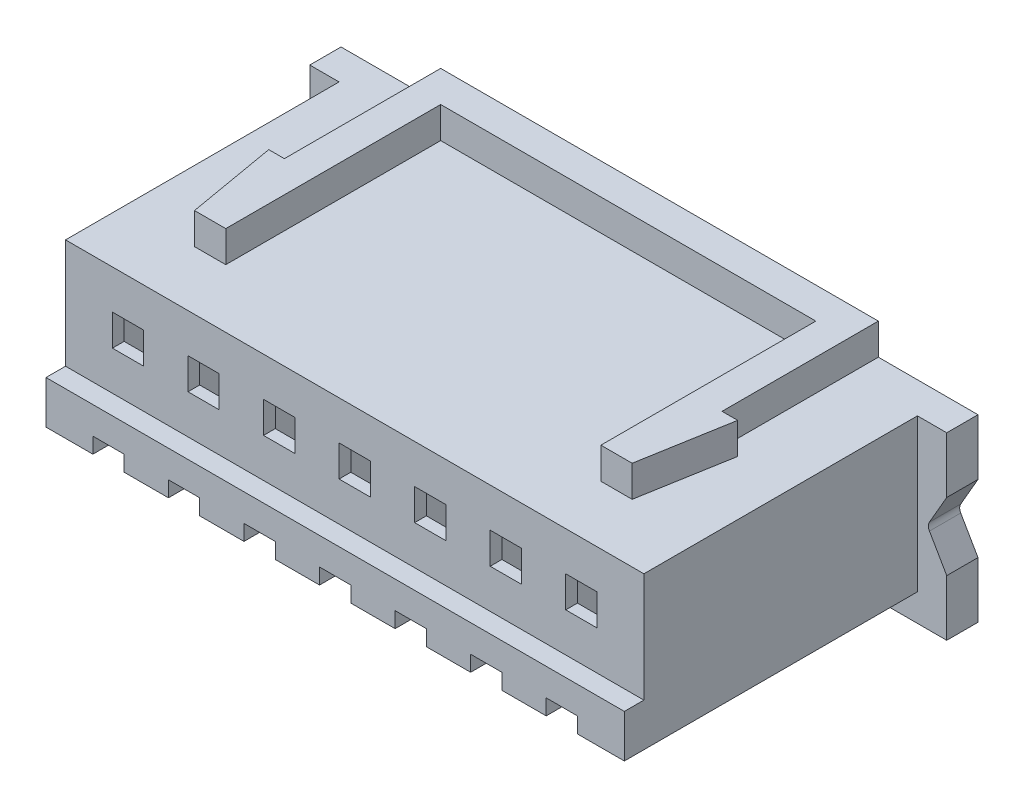
from build123d import *

# Parameters (mm, degrees)
SKETCH1_W           = 14.8
SKETCH1_H           = 4.3
BOSS_EXTRUDE1_DEPTH = 7
SKETCH2_W           = 16.3
SKETCH2_H           = 4.6
BOSS_EXTRUDE2_DEPTH = 0.8
CUT_EXTRUDE1_DEPTH  = 1
FILLET1_R           = 0.2
SKETCH4_W           = 14.8
SKETCH4_H           = 1.5
BOSS_EXTRUDE3_DEPTH = 0.5
SKETCH5_W           = 0.8
SKETCH5_H           = 0.8
CUT_EXTRUDE2_DEPTH  = 3.2
SKETCH6_W           = 0.8
SKETCH6_H           = 0.8
CUT_EXTRUDE3_DEPTH  = 10
BOSS_EXTRUDE4_DEPTH = 0.8
CUT_EXTRUDE4_DEPTH  = 7.5
CUT_EXTRUDE5_DEPTH  = 0.4
BOSS_EXTRUDE5_DEPTH = 0.1


with BuildPart() as part:
    # Sketch1 → Boss-Extrude1 (new body)
    with BuildSketch(Plane.XY):
        Rectangle(SKETCH1_W, SKETCH1_H)
    extrude(amount=BOSS_EXTRUDE1_DEPTH)

    # Sketch2 → Boss-Extrude2 (add)
    with BuildSketch(Plane(origin=(0, 0, 0), x_dir=(-1, 0, 0), z_dir=(0, 0, -1))):
        with Locations((0, -0.15)):
            Rectangle(SKETCH2_W, SKETCH2_H)
    extrude(amount=BOSS_EXTRUDE2_DEPTH)

    # Sketch3 → Cut-Extrude1 (cut)
    with BuildSketch(Plane.XY):
        Polygon((7.65, -0.15), (8.15, -1.016025404), (8.15, 0.716025404), align=None)
    extrude(amount=-CUT_EXTRUDE1_DEPTH, mode=Mode.SUBTRACT)

    # Fillet1
    fillet1_edges = [part.edges().sort_by_distance(p)[0] for p in [
        (7.65, -0.15, -0.4),
    ]]
    fillet(fillet1_edges, radius=FILLET1_R)

    # Sketch4 → Boss-Extrude3 (add)
    with BuildSketch(Plane.XY.offset(7)):
        with Locations((0, -1.4)):
            Rectangle(SKETCH4_W, SKETCH4_H)
    extrude(amount=BOSS_EXTRUDE3_DEPTH)

    # Sketch5 → Cut-Extrude2 (cut)
    with BuildSketch(Plane.XY.offset(7.5)):
        with Locations((3.866666667, -1.75)):
            Rectangle(SKETCH5_W, SKETCH5_H)
        with Locations((1.933333333, -1.75)):
            Rectangle(SKETCH5_W, SKETCH5_H)
        with Locations((0, -1.75)):
            Rectangle(SKETCH5_W, SKETCH5_H)
        with Locations((-1.933333333, -1.75)):
            Rectangle(SKETCH5_W, SKETCH5_H)
        with Locations((5.8, -1.75)):
            Rectangle(SKETCH5_W, SKETCH5_H)
        with Locations((-3.866666667, -1.75)):
            Rectangle(SKETCH5_W, SKETCH5_H)
        with Locations((-5.8, -1.75)):
            Rectangle(SKETCH5_W, SKETCH5_H)
    extrude(amount=-CUT_EXTRUDE2_DEPTH, mode=Mode.SUBTRACT)

    # Sketch6 → Cut-Extrude3 (cut)
    with BuildSketch(Plane.XY.offset(7)):
        with Locations((-5.8, 0.75)):
            Rectangle(SKETCH6_W, SKETCH6_H)
        with Locations((-3.866666667, 0.75)):
            Rectangle(SKETCH6_W, SKETCH6_H)
        with Locations((-1.933333333, 0.75)):
            Rectangle(SKETCH6_W, SKETCH6_H)
        with Locations((0, 0.75)):
            Rectangle(SKETCH6_W, SKETCH6_H)
        with Locations((1.933333333, 0.75)):
            Rectangle(SKETCH6_W, SKETCH6_H)
        with Locations((3.866666667, 0.75)):
            Rectangle(SKETCH6_W, SKETCH6_H)
        with Locations((5.8, 0.75)):
            Rectangle(SKETCH6_W, SKETCH6_H)
    extrude(amount=-CUT_EXTRUDE3_DEPTH, mode=Mode.SUBTRACT)

    # Sketch7 → Boss-Extrude4 (add)
    with BuildSketch(Plane(origin=(0, 2.15, 0), x_dir=(1, 0, 0), z_dir=(0, 1, 0))):
        Polygon((-5.6, -5.5), (-6, -3.2), (-5.6, -3.2), (-5.6, 0.8), (5.6, 0.8), (5.6, -3.2), (6, -3.2), (5.6, -5.5), (4.8, -5.5), (4.8, 0), (-4.8, 0), (-4.8, -5.5), align=None)
    extrude(amount=BOSS_EXTRUDE4_DEPTH)

    # Sketch8 → Cut-Extrude4 (cut)
    with BuildSketch(Plane(origin=(0, 0, -0.8), x_dir=(-1, 0, 0), z_dir=(0, 0, -1))):
        Polygon((4.8, 1.85), (2.933333333, 1.85), (2.933333333, -0.95), (3.466666667, -0.95), (3.466666667, -1.35), (4.266666667, -1.35), (4.266666667, -0.95), (4.8, -0.95), align=None)
        Polygon((6.8, 1.85), (4.866666667, 1.85), (4.866666667, -0.95), (5.4, -0.95), (5.4, -1.35), (6.2, -1.35), (6.2, -0.95), (6.8, -0.95), align=None)
        Polygon((2.866666667, 1.85), (2.866666667, -0.95), (2.333333333, -0.95), (2.333333333, -1.35), (1.533333333, -1.35), (1.533333333, -0.95), (1, -0.95), (1, 1.85), align=None)
        Polygon((0.933333333, 1.85), (0.933333333, -0.95), (0.4, -0.95), (0.4, -1.35), (-0.4, -1.35), (-0.4, -0.95), (-0.933333333, -0.95), (-0.933333333, 1.85), align=None)
        Polygon((-1, 1.85), (-1, -0.95), (-1.533333333, -0.95), (-1.533333333, -1.35), (-2.333333333, -1.35), (-2.333333333, -0.95), (-2.866666667, -0.95), (-2.866666667, 1.85), align=None)
        Polygon((-2.933333333, 1.85), (-2.933333333, -0.95), (-3.466666667, -0.95), (-3.466666667, -1.35), (-4.266666667, -1.35), (-4.266666667, -0.95), (-4.8, -0.95), (-4.8, 1.85), align=None)
        Polygon((-4.866666667, 1.85), (-4.866666667, -0.95), (-5.4, -0.95), (-5.4, -1.35), (-6.2, -1.35), (-6.2, -0.95), (-6.8, -0.95), (-6.8, 1.85), align=None)
    extrude(amount=-CUT_EXTRUDE4_DEPTH, mode=Mode.SUBTRACT)

    # Sketch9 → Cut-Extrude5 (cut)
    with BuildSketch(Plane.XZ.offset(2.15)):
        Polygon((-6.2, 7.5), (-7.4, 7.5), (-7.4, 0), (7.4, 0), (7.4, 7.5), (6.2, 7.5), (6.2, 4.3), (5.4, 4.3), (5.4, 7.5), (4.266666667, 7.5), (4.266666667, 4.3), (3.466666667, 4.3), (3.466666667, 7.5), (2.333333333, 7.5), (2.333333333, 4.3), (1.533333333, 4.3), (1.533333333, 7.5), (0.4, 7.5), (0.4, 4.3), (-0.4, 4.3), (-0.4, 7.5), (-1.533333333, 7.5), (-1.533333333, 4.3), (-2.333333333, 4.3), (-2.333333333, 7.5), (-3.466666667, 7.5), (-3.466666667, 4.3), (-4.266666667, 4.3), (-4.266666667, 7.5), (-5.4, 7.5), (-5.4, 4.3), (-6.2, 4.3), align=None)
    extrude(amount=-CUT_EXTRUDE5_DEPTH, mode=Mode.SUBTRACT)

    # Sketch10 → Boss-Extrude5 (add)
    with BuildSketch(Plane(origin=(0, 0, -0.8), x_dir=(-1, 0, 0), z_dir=(0, 0, -1))):
        Polygon((-5.805978759, -1.515739488), (-5.713530843, -1.515739488), (-5.713530843, -2.015739488), (-5.758402638, -2.015739488), (-5.758402638, -1.567021539), (-5.835325715, -1.567021539), align=None)
        with BuildLine():
            Line((-3.925069304, -1.669585642), (-3.969941099, -1.669585642))
            add(Edge.make_bspline(
                [(-3.969941099, -1.669585642), (-3.969648649, -1.663632658), (-3.969074284, -1.651941156), (-3.966384528, -1.634894883), (-3.962535832, -1.618601341), (-3.957094195, -1.603191353), (-3.950336156, -1.588528666), (-3.942231866, -1.574671521), (-3.932632744, -1.56167278), (-3.921746068, -1.549652945), (-3.909921977, -1.538626149), (-3.897163986, -1.529103972), (-3.883757553, -1.52105859), (-3.869743353, -1.514332698), (-3.854963273, -1.509284149), (-3.839551436, -1.505538201), (-3.823440131, -1.503284437), (-3.812462985, -1.503042182), (-3.806880202, -1.502918975)],
                knots=[0, 0, 0, 0, 1.7869e-05, 3.5094e-05, 5.1686e-05, 6.8032e-05, 8.4031e-05, 0.000100058, 0.000116104, 0.000132416, 0.000148647, 0.000164532, 0.000180078, 0.00019549, 0.000211074, 0.000226841, 0.000243017, 0.000259759, 0.000259759, 0.000259759, 0.000259759], degree=3))
            add(Edge.make_bspline(
                [(-3.806880202, -1.502918975), (-3.80139762, -1.503047326), (-3.790624542, -1.503299531), (-3.774901397, -1.505465392), (-3.759933212, -1.50885762), (-3.745749245, -1.513616965), (-3.732462665, -1.52001474), (-3.719973658, -1.527700103), (-3.708133543, -1.53658865), (-3.697475431, -1.547053481), (-3.687688562, -1.55822525), (-3.679245383, -1.570152093), (-3.672014931, -1.582470563), (-3.66598812, -1.595274592), (-3.661551528, -1.608684738), (-3.658183213, -1.622505767), (-3.656279297, -1.63688074), (-3.655987093, -1.646610248), (-3.655838535, -1.651556796)],
                knots=[0, 0, 0, 0, 1.6441e-05, 3.2306e-05, 4.7516e-05, 6.2435e-05, 7.7085e-05, 9.1652e-05, 0.000106376, 0.000121393, 0.000136374, 0.000150882, 0.000165157, 0.000179183, 0.000193247, 0.000207458, 0.000221808, 0.000236648, 0.000236648, 0.000236648, 0.000236648], degree=3))
            add(Edge.make_bspline(
                [(-3.655838535, -1.651556796), (-3.65608043, -1.658520772), (-3.656559974, -1.672326517), (-3.660662028, -1.692614354), (-3.667068673, -1.712270557), (-3.674782581, -1.728090172), (-3.682564358, -1.740837814), (-3.689576859, -1.751333343), (-3.697786118, -1.762634124), (-3.707311618, -1.774702315), (-3.717956314, -1.787632444), (-3.729816623, -1.801416701), (-3.74297712, -1.815912668), (-3.752214049, -1.825813468), (-3.757000394, -1.830943815)],
                knots=[0, 0, 0, 0, 2.0874e-05, 4.1382e-05, 6.1843e-05, 8.2763e-05, 9.3997e-05, 0.000106637, 0.000120621, 0.000135888, 0.000152753, 0.000170863, 0.000190435, 0.000211484, 0.000211484, 0.000211484, 0.000211484], degree=3))
            Line((-3.757000394, -1.830943815), (-3.882100554, -1.964457437))
            Line((-3.882100554, -1.964457437), (-3.649428279, -1.964457437))
            Line((-3.649428279, -1.964457437), (-3.649428279, -2.015739488))
            Line((-3.649428279, -2.015739488), (-3.989171868, -2.015739488))
            Line((-3.989171868, -2.015739488), (-3.795261612, -1.808808398))
            add(Edge.make_bspline(
                [(-3.795261612, -1.808808398), (-3.790540485, -1.803880069), (-3.781472167, -1.794413756), (-3.768646085, -1.780593333), (-3.757126229, -1.76777197), (-3.74683803, -1.755973892), (-3.738004672, -1.745026525), (-3.730165782, -1.735284425), (-3.723884983, -1.726319503), (-3.717068498, -1.715927987), (-3.710466501, -1.703240513), (-3.704793307, -1.6877357), (-3.701334043, -1.671774664), (-3.700919067, -1.660988659), (-3.70071033, -1.655563206)],
                knots=[0, 0, 0, 0, 2.0474e-05, 3.9327e-05, 5.6561e-05, 7.2184e-05, 8.6278e-05, 9.8762e-05, 0.000109683, 0.000119101, 0.000136035, 0.000152448, 0.000168517, 0.00018478, 0.00018478, 0.00018478, 0.00018478], degree=3))
            add(Edge.make_bspline(
                [(-3.70071033, -1.655563206), (-3.70080115, -1.652151578), (-3.70098014, -1.645427913), (-3.702559811, -1.635569948), (-3.704947026, -1.626060689), (-3.708367777, -1.616870886), (-3.712883026, -1.608092935), (-3.718379223, -1.599716153), (-3.72472066, -1.591617729), (-3.732056556, -1.584024401), (-3.740115345, -1.577069943), (-3.748628809, -1.570909359), (-3.757635967, -1.565760915), (-3.767098841, -1.561540415), (-3.776991051, -1.558229646), (-3.787331729, -1.555935564), (-3.798092303, -1.554495209), (-3.805439945, -1.554300327), (-3.809183888, -1.554201026)],
                knots=[0, 0, 0, 0, 1.0229e-05, 2.0159e-05, 2.9876e-05, 3.9606e-05, 4.9505e-05, 5.9423e-05, 6.9622e-05, 8.0319e-05, 9.1042e-05, 0.000101521, 0.000111795, 0.000122107, 0.000132559, 0.000143032, 0.000153841, 0.00016507, 0.00016507, 0.00016507, 0.00016507], degree=3))
            add(Edge.make_bspline(
                [(-3.809183888, -1.554201026), (-3.813094007, -1.554303174), (-3.820772835, -1.554503775), (-3.832046982, -1.555907012), (-3.842802093, -1.558327847), (-3.853065222, -1.5616388), (-3.862853735, -1.565847164), (-3.872120027, -1.571088842), (-3.880843296, -1.577343627), (-3.889039943, -1.584435135), (-3.89659194, -1.592330506), (-3.903227208, -1.60113193), (-3.909024924, -1.610678703), (-3.914083386, -1.620945068), (-3.918191342, -1.632024179), (-3.921330363, -1.643876708), (-3.923814198, -1.656451192), (-3.924643987, -1.665134775), (-3.925069304, -1.669585642)],
                knots=[0, 0, 0, 0, 1.1729e-05, 2.3035e-05, 3.4018e-05, 4.4756e-05, 5.5343e-05, 6.5928e-05, 7.6628e-05, 8.7492e-05, 9.8403e-05, 0.00010934, 0.000120489, 0.000131867, 0.000143625, 0.00015587, 0.000168619, 0.000182025, 0.000182025, 0.000182025, 0.000182025], degree=3))
        make_face()
        with BuildLine():
            Line((-2.001992381, -1.631124103), (-2.046864176, -1.631124103))
            add(Edge.make_bspline(
                [(-2.046864176, -1.631124103), (-2.045648526, -1.626090891), (-2.04327203, -1.616251374), (-2.038315233, -1.602193193), (-2.03291534, -1.588889833), (-2.026431182, -1.576590394), (-2.019358503, -1.565047694), (-2.011255257, -1.554523533), (-2.002495296, -1.544750252), (-1.992806018, -1.536076933), (-1.982644781, -1.528222971), (-1.971868406, -1.521526535), (-1.960693707, -1.515765941), (-1.94904326, -1.511020194), (-1.936882378, -1.507445119), (-1.924321003, -1.50485129), (-1.911326218, -1.503166845), (-1.902505133, -1.50300245), (-1.898026035, -1.502918975)],
                knots=[0, 0, 0, 0, 1.5524e-05, 3.0347e-05, 4.467e-05, 5.8558e-05, 7.201e-05, 8.5231e-05, 9.8349e-05, 0.000111325, 0.000124187, 0.000136831, 0.000149329, 0.000161865, 0.00017451, 0.000187298, 0.000200318, 0.000213748, 0.000213748, 0.000213748, 0.000213748], degree=3))
            add(Edge.make_bspline(
                [(-1.898026035, -1.502918975), (-1.891499929, -1.503116008), (-1.87859007, -1.503505776), (-1.859623921, -1.507064981), (-1.841334375, -1.512697143), (-1.823921626, -1.520479104), (-1.807747564, -1.530077292), (-1.79335668, -1.541500825), (-1.780944036, -1.554529297), (-1.770530553, -1.568919663), (-1.762376982, -1.584299022), (-1.756364643, -1.600127616), (-1.752704403, -1.616367897), (-1.752230037, -1.627333223), (-1.751992381, -1.632826828)],
                knots=[0, 0, 0, 0, 1.9562e-05, 3.8698e-05, 5.7675e-05, 7.6865e-05, 9.5777e-05, 0.000113954, 0.000131807, 0.000149598, 0.000167073, 0.000183872, 0.000200276, 0.000216747, 0.000216747, 0.000216747, 0.000216747], degree=3))
            add(Edge.make_bspline(
                [(-1.751992381, -1.632826828), (-1.752158609, -1.638113513), (-1.75248389, -1.648458735), (-1.755245848, -1.663561806), (-1.759893885, -1.67779632), (-1.766332423, -1.6912222), (-1.77466693, -1.70375432), (-1.784763029, -1.715420876), (-1.796691981, -1.726273613), (-1.805731829, -1.732490681), (-1.810385811, -1.735691411)],
                knots=[0, 0, 0, 0, 1.5851e-05, 3.1018e-05, 4.5873e-05, 6.0656e-05, 7.5546e-05, 9.0886e-05, 0.000106841, 0.00012377, 0.00012377, 0.00012377, 0.00012377], degree=3))
            add(Edge.make_bspline(
                [(-1.810385811, -1.735691411), (-1.805066989, -1.738259721), (-1.794528864, -1.743348287), (-1.780164502, -1.753327681), (-1.767124806, -1.764850016), (-1.759852846, -1.773841823), (-1.756199112, -1.77835968)],
                knots=[0, 0, 0, 0, 1.7695e-05, 3.5058e-05, 5.2293e-05, 6.9697e-05, 6.9697e-05, 6.9697e-05, 6.9697e-05], degree=3))
            add(Edge.make_bspline(
                [(-1.756199112, -1.77835968), (-1.753793206, -1.781653645), (-1.749020792, -1.788187633), (-1.743130002, -1.798692837), (-1.737785843, -1.809314478), (-1.733621525, -1.82033725), (-1.730396687, -1.831633395), (-1.72809154, -1.843222309), (-1.72665952, -1.855113455), (-1.726454441, -1.863158095), (-1.726351356, -1.867201828)],
                knots=[0, 0, 0, 0, 1.2226e-05, 2.4252e-05, 3.6078e-05, 4.7871e-05, 5.9538e-05, 7.1285e-05, 8.3286e-05, 9.5416e-05, 9.5416e-05, 9.5416e-05, 9.5416e-05], degree=3))
            add(Edge.make_bspline(
                [(-1.726351356, -1.867201828), (-1.726607715, -1.874203216), (-1.727119226, -1.888173045), (-1.731691237, -1.908812291), (-1.738778843, -1.928987363), (-1.748844119, -1.948283769), (-1.761110906, -1.966338109), (-1.77570481, -1.982491867), (-1.792460011, -1.996377382), (-1.811146532, -2.007978843), (-1.831391836, -2.017252832), (-1.853045492, -2.02368961), (-1.8757955, -2.027881895), (-1.891396543, -2.028331448), (-1.899328118, -2.028560001)],
                knots=[0, 0, 0, 0, 2.098e-05, 4.1862e-05, 6.3119e-05, 8.498e-05, 0.000106955, 0.000128441, 0.000150062, 0.000172018, 0.00019425, 0.000216652, 0.00023964, 0.000263413, 0.000263413, 0.000263413, 0.000263413], degree=3))
            add(Edge.make_bspline(
                [(-1.899328118, -2.028560001), (-1.904673733, -2.02843597), (-1.915192119, -2.02819192), (-1.930655476, -2.026523548), (-1.945415719, -2.023476404), (-1.959492804, -2.019375932), (-1.972899238, -2.014177112), (-1.98559411, -2.007703012), (-1.997655524, -2.000087083), (-2.008969659, -1.991239428), (-2.019535169, -1.981342094), (-2.029071273, -1.970219378), (-2.037736957, -1.958076892), (-2.045300191, -1.944773598), (-2.05210547, -1.930481418), (-2.05770275, -1.915017347), (-2.06262926, -1.89851963), (-2.064919755, -1.88702281), (-2.066094945, -1.881124103)],
                knots=[0, 0, 0, 0, 1.6037e-05, 3.1555e-05, 4.6582e-05, 6.1194e-05, 7.5497e-05, 8.9652e-05, 0.000103879, 0.000118224, 0.000132679, 0.000147236, 0.000162105, 0.000177361, 0.000193087, 0.000209535, 0.00022665, 0.000244684, 0.000244684, 0.000244684, 0.000244684], degree=3))
            Line((-2.066094945, -1.881124103), (-2.02122315, -1.881124103))
            add(Edge.make_bspline(
                [(-2.02122315, -1.881124103), (-2.020054109, -1.884973962), (-2.017780221, -1.892462273), (-2.013909607, -1.903239459), (-2.009499854, -1.913119181), (-2.004769203, -1.922173913), (-1.999800854, -1.930492827), (-1.994241578, -1.937855951), (-1.988503129, -1.944586695), (-1.984177507, -1.948378782), (-1.98206049, -1.95023468)],
                knots=[0, 0, 0, 0, 1.207e-05, 2.3476e-05, 3.4328e-05, 4.4497e-05, 5.4117e-05, 6.3352e-05, 7.2152e-05, 8.0588e-05, 8.0588e-05, 8.0588e-05, 8.0588e-05], degree=3))
            add(Edge.make_bspline(
                [(-1.98206049, -1.95023468), (-1.979260979, -1.952393014), (-1.973670599, -1.956703018), (-1.964560852, -1.962203251), (-1.954980154, -1.966969112), (-1.944720914, -1.97060964), (-1.934004519, -1.973692163), (-1.922657752, -1.97570938), (-1.910780721, -1.977093404), (-1.902671041, -1.977215537), (-1.898526836, -1.977277949)],
                knots=[0, 0, 0, 0, 1.0597e-05, 2.1162e-05, 3.1867e-05, 4.2641e-05, 5.3771e-05, 6.5283e-05, 7.7174e-05, 8.96e-05, 8.96e-05, 8.96e-05, 8.96e-05], degree=3))
            add(Edge.make_bspline(
                [(-1.898526836, -1.977277949), (-1.893847765, -1.977189963), (-1.884698244, -1.977017913), (-1.871347549, -1.975435669), (-1.858646485, -1.973131324), (-1.846736068, -1.969572327), (-1.835460281, -1.965175062), (-1.824977188, -1.959653862), (-1.815149173, -1.953176044), (-1.806102115, -1.945813307), (-1.797967042, -1.937753094), (-1.790804255, -1.929322655), (-1.784715017, -1.920557537), (-1.779803078, -1.911409234), (-1.775924428, -1.901915629), (-1.77328397, -1.892050082), (-1.77144804, -1.88189333), (-1.771298524, -1.874989192), (-1.77122315, -1.871508719)],
                knots=[0, 0, 0, 0, 1.4031e-05, 2.7437e-05, 4.0284e-05, 5.2708e-05, 6.4668e-05, 7.654e-05, 8.818e-05, 9.9927e-05, 0.000111472, 0.000122488, 0.000133073, 0.000143425, 0.000153581, 0.000163762, 0.000174021, 0.000184449, 0.000184449, 0.000184449, 0.000184449], degree=3))
            add(Edge.make_bspline(
                [(-1.77122315, -1.871508719), (-1.771441765, -1.866849956), (-1.771877906, -1.857555612), (-1.775207703, -1.843881673), (-1.780684684, -1.8307069), (-1.788352185, -1.818256072), (-1.797685861, -1.806716658), (-1.808595133, -1.796420732), (-1.821170595, -1.787925005), (-1.832744862, -1.782055197), (-1.842997027, -1.7780499), (-1.851770653, -1.775382048), (-1.861593025, -1.773122954), (-1.872345361, -1.771021201), (-1.884108677, -1.769232437), (-1.896870168, -1.767740749), (-1.91063242, -1.766547172), (-1.920159729, -1.766014158), (-1.925069304, -1.765739488)],
                knots=[0, 0, 0, 0, 1.3966e-05, 2.7862e-05, 4.1962e-05, 5.6614e-05, 7.1569e-05, 8.6379e-05, 0.000101437, 0.000116935, 0.000125212, 0.000134432, 0.000144417, 0.000155437, 0.000167294, 0.000180102, 0.000193977, 0.000208728, 0.000208728, 0.000208728, 0.000208728], degree=3))
            Line((-1.925069304, -1.765739488), (-1.925069304, -1.714457437))
            add(Edge.make_bspline(
                [(-1.925069304, -1.714457437), (-1.918883424, -1.714352465), (-1.906766803, -1.71414685), (-1.889067616, -1.711659992), (-1.872142857, -1.708219902), (-1.856367608, -1.702950589), (-1.841989221, -1.696830546), (-1.829514992, -1.689708802), (-1.819119685, -1.681792409), (-1.810853818, -1.67295918), (-1.804635357, -1.663485601), (-1.800088671, -1.653611793), (-1.79740291, -1.643251213), (-1.797044387, -1.636180546), (-1.796864176, -1.632626507)],
                knots=[0, 0, 0, 0, 1.8543e-05, 3.6321e-05, 5.353e-05, 7.0285e-05, 8.612e-05, 0.000100345, 0.000113267, 0.000125173, 0.000136452, 0.00014712, 0.000157663, 0.000168319, 0.000168319, 0.000168319, 0.000168319], degree=3))
            add(Edge.make_bspline(
                [(-1.796864176, -1.632626507), (-1.796923378, -1.630015401), (-1.797041156, -1.624820728), (-1.798526482, -1.617231433), (-1.800758488, -1.609874155), (-1.80382702, -1.602780182), (-1.807934192, -1.595998714), (-1.812849333, -1.589471936), (-1.818701918, -1.58323711), (-1.825408411, -1.577425636), (-1.832610097, -1.571887173), (-1.840502922, -1.567185225), (-1.848848904, -1.563164502), (-1.857657284, -1.559848859), (-1.866956645, -1.557354675), (-1.876703296, -1.555563841), (-1.886915822, -1.554444176), (-1.893883213, -1.554282973), (-1.897425074, -1.554201026)],
                knots=[0, 0, 0, 0, 7.823e-06, 1.5563e-05, 2.3104e-05, 3.0863e-05, 3.8679e-05, 4.6832e-05, 5.5336e-05, 6.4278e-05, 7.3432e-05, 8.2553e-05, 9.1782e-05, 0.000101195, 0.000110744, 0.000120626, 0.000130901, 0.000141526, 0.000141526, 0.000141526, 0.000141526], degree=3))
            add(Edge.make_bspline(
                [(-1.897425074, -1.554201026), (-1.903118169, -1.554399792), (-1.914238108, -1.554788029), (-1.930268811, -1.558188459), (-1.945171573, -1.5636139), (-1.956562811, -1.570090045), (-1.964974607, -1.576482964), (-1.970985598, -1.582066162), (-1.976888529, -1.588270852), (-1.982295054, -1.595479191), (-1.987762765, -1.603203018), (-1.992740559, -1.611834973), (-1.997577658, -1.621149886), (-2.000492308, -1.627734977), (-2.001992381, -1.631124103)],
                knots=[0, 0, 0, 0, 1.7063e-05, 3.3328e-05, 4.8919e-05, 6.4486e-05, 7.2419e-05, 8.0571e-05, 8.9075e-05, 9.807e-05, 0.000107572, 0.00011745, 0.000127932, 0.000139048, 0.000139048, 0.000139048, 0.000139048], degree=3))
        make_face()
        Polygon((0.129918676, -1.502918975), (0.13903326, -1.502918975), (0.13903326, -1.849072821), (0.196725567, -1.849072821), (0.196725567, -1.900354873), (0.13903326, -1.900354873), (0.13903326, -2.015739488), (0.094161465, -2.015739488), (0.094161465, -1.900354873), (-0.143018022, -1.900354873), align=None)
        Polygon((0.094161465, -1.849072821), (0.094161465, -1.631925385), (-0.054876997, -1.849072821), align=None, mode=Mode.SUBTRACT)
        with BuildLine():
            Line((2.094161465, -1.515739488), (2.094161465, -1.567021539))
            Line((2.094161465, -1.567021539), (1.92408935, -1.567021539))
            Line((1.92408935, -1.567021539), (1.897146241, -1.698531956))
            add(Edge.make_bspline(
                [(1.897146241, -1.698531956), (1.902439937, -1.697070488), (1.912695636, -1.694239127), (1.927832759, -1.691095445), (1.942203074, -1.689200382), (1.951528127, -1.688941623), (1.956040471, -1.688816411)],
                knots=[0, 0, 0, 0, 1.6472e-05, 3.1911e-05, 4.6347e-05, 5.9882e-05, 5.9882e-05, 5.9882e-05, 5.9882e-05], degree=3))
            add(Edge.make_bspline(
                [(1.956040471, -1.688816411), (1.961623863, -1.688937259), (1.972602205, -1.689174876), (1.988664912, -1.691456569), (2.003998182, -1.695047985), (2.01856995, -1.700065203), (2.032407171, -1.706480879), (2.045382537, -1.714495156), (2.05769081, -1.723857061), (2.069111181, -1.734620634), (2.079471796, -1.746466579), (2.088581223, -1.759203418), (2.096318736, -1.772707369), (2.102541701, -1.787107456), (2.107510892, -1.802244478), (2.11081832, -1.818277704), (2.113020707, -1.835056007), (2.113266762, -1.846528089), (2.113392234, -1.85237811)],
                knots=[0, 0, 0, 0, 1.6741e-05, 3.2918e-05, 4.8563e-05, 6.3926e-05, 7.9071e-05, 9.4222e-05, 0.000109587, 0.000125389, 0.000141218, 0.000156727, 0.000172294, 0.000187813, 0.000203714, 0.000219999, 0.000236858, 0.0002544, 0.0002544, 0.0002544, 0.0002544], degree=3))
            add(Edge.make_bspline(
                [(2.113392234, -1.85237811), (2.113297223, -1.856452713), (2.113108486, -1.864546854), (2.112148688, -1.876567454), (2.110300728, -1.888333573), (2.107819625, -1.899846772), (2.104599279, -1.911085253), (2.100700843, -1.922081186), (2.095929982, -1.93276613), (2.090696928, -1.943241186), (2.084804574, -1.953269544), (2.078264788, -1.962647971), (2.071355432, -1.971517154), (2.063920948, -1.979781973), (2.055892234, -1.987388119), (2.047366525, -1.99438073), (2.038411851, -2.000878063), (2.028889673, -2.006616377), (2.019012176, -2.011896799), (2.008636716, -2.016228733), (1.997999473, -2.020101665), (1.986947348, -2.023188741), (1.975505375, -2.025607677), (1.963654693, -2.02725062), (1.951457454, -2.028447254), (1.943189595, -2.028522162), (1.939013228, -2.028560001)],
                knots=[0, 0, 0, 0, 1.2226e-05, 2.4287e-05, 3.6144e-05, 4.7931e-05, 5.9598e-05, 7.1193e-05, 8.2899e-05, 9.4679e-05, 0.000106309, 0.000117755, 0.000128956, 0.000140019, 0.000151071, 0.0001621, 0.00017308, 0.000184228, 0.000195429, 0.000206647, 0.000217926, 0.000229373, 0.000241041, 0.000252982, 0.000265251, 0.000277775, 0.000277775, 0.000277775, 0.000277775], degree=3))
            add(Edge.make_bspline(
                [(1.939013228, -2.028560001), (1.934031202, -2.02846131), (1.924229655, -2.028267146), (1.909869574, -2.026235934), (1.896053201, -2.023326803), (1.882891758, -2.018950193), (1.870267292, -2.013466294), (1.858349761, -2.006535412), (1.84683465, -1.998681255), (1.836190073, -1.989412633), (1.826310629, -1.979281821), (1.817466842, -1.968287873), (1.809590616, -1.956612238), (1.802808081, -1.944198216), (1.79702265, -1.931078426), (1.792477651, -1.917203711), (1.788809315, -1.902646568), (1.787257398, -1.892624638), (1.786469157, -1.88753436)],
                knots=[0, 0, 0, 0, 1.4936e-05, 2.9385e-05, 4.3432e-05, 5.7242e-05, 7.092e-05, 8.4648e-05, 9.854e-05, 0.000112674, 0.000126911, 0.000140942, 0.000154943, 0.000169108, 0.000183326, 0.000197895, 0.00021286, 0.000228305, 0.000228305, 0.000228305, 0.000228305], degree=3))
            Line((1.786469157, -1.88753436), (1.831340952, -1.88753436))
            add(Edge.make_bspline(
                [(1.831340952, -1.88753436), (1.832445032, -1.892302424), (1.834567134, -1.901466909), (1.839225098, -1.914342815), (1.844920223, -1.92581699), (1.851692273, -1.936041216), (1.859770849, -1.944956787), (1.868989339, -1.952902082), (1.879324728, -1.960069957), (1.890809475, -1.966044638), (1.902925629, -1.971140175), (1.915606659, -1.974533274), (1.92850728, -1.976919116), (1.937232761, -1.977157939), (1.941617394, -1.977277949)],
                knots=[0, 0, 0, 0, 1.4673e-05, 2.8202e-05, 4.0968e-05, 5.3024e-05, 6.4869e-05, 7.6939e-05, 8.9469e-05, 0.000102507, 0.000115713, 0.000128811, 0.00014182, 0.00015496, 0.00015496, 0.00015496, 0.00015496], degree=3))
            add(Edge.make_bspline(
                [(1.941617394, -1.977277949), (1.945897172, -1.977160695), (1.95432409, -1.976929821), (1.966725716, -1.97515282), (1.978698984, -1.972416024), (1.990125749, -1.96832033), (2.001205969, -1.963342513), (2.011659365, -1.956954645), (2.021788347, -1.949603214), (2.031278081, -1.941180838), (2.039969431, -1.931899453), (2.047648877, -1.921974112), (2.054045578, -1.911385991), (2.059436165, -1.900318397), (2.063529494, -1.888650032), (2.066449634, -1.876435578), (2.068164357, -1.863644867), (2.06840024, -1.85492068), (2.068520439, -1.850475065)],
                knots=[0, 0, 0, 0, 1.2835e-05, 2.5271e-05, 3.7516e-05, 4.9617e-05, 6.1628e-05, 7.3893e-05, 8.6294e-05, 9.9136e-05, 0.000111892, 0.000124393, 0.000136709, 0.000148939, 0.000161262, 0.000173724, 0.000186558, 0.000199893, 0.000199893, 0.000199893, 0.000199893], degree=3))
            add(Edge.make_bspline(
                [(2.068520439, -1.850475065), (2.068426371, -1.846464243), (2.068242245, -1.83861363), (2.066737878, -1.82712803), (2.064121168, -1.816260452), (2.060489185, -1.805958419), (2.055877826, -1.796212213), (2.050242639, -1.787011775), (2.043477868, -1.778478371), (2.035750455, -1.770608006), (2.027285021, -1.763344452), (2.017935915, -1.75715244), (2.007898782, -1.751943309), (1.997294554, -1.747447881), (1.985870997, -1.744219203), (1.973854335, -1.741795219), (1.961114805, -1.740393024), (1.952404707, -1.740198469), (1.947927491, -1.740098462)],
                knots=[0, 0, 0, 0, 1.203e-05, 2.3546e-05, 3.4673e-05, 4.5507e-05, 5.6259e-05, 6.6962e-05, 7.7802e-05, 8.8851e-05, 0.000100009, 0.000111204, 0.000122404, 0.0001339, 0.000145691, 0.000157948, 0.000170646, 0.000184077, 0.000184077, 0.000184077, 0.000184077], degree=3))
            add(Edge.make_bspline(
                [(1.947927491, -1.740098462), (1.944051929, -1.740181404), (1.936049879, -1.740352657), (1.923775189, -1.741613585), (1.910876371, -1.74364777), (1.897402872, -1.746445806), (1.883314228, -1.750107388), (1.868640171, -1.754495174), (1.853349847, -1.759741174), (1.843047315, -1.763702918), (1.837751208, -1.765739488)],
                knots=[0, 0, 0, 0, 1.1625e-05, 2.4004e-05, 3.698e-05, 5.0789e-05, 6.5268e-05, 8.0637e-05, 9.6727e-05, 0.000113749, 0.000113749, 0.000113749, 0.000113749], degree=3))
            Line((1.837751208, -1.765739488), (1.88903326, -1.515739488))
            Line((1.88903326, -1.515739488), (2.094161465, -1.515739488))
        make_face()
        with BuildLine():
            Line((3.933905055, -1.502918975), (3.968460343, -1.530062405))
            Line((3.968460343, -1.530062405), (3.836348965, -1.732085642))
            add(Edge.make_bspline(
                [(3.836348965, -1.732085642), (3.845144719, -1.730683662), (3.862301831, -1.727948941), (3.879668388, -1.727497806), (3.888131817, -1.727277949)],
                knots=[0, 0, 0, 0, 2.6687e-05, 5.2056e-05, 5.2056e-05, 5.2056e-05, 5.2056e-05], degree=3))
            add(Edge.make_bspline(
                [(3.888131817, -1.727277949), (3.893213603, -1.727414537), (3.903216946, -1.727683405), (3.917903632, -1.729752527), (3.932016337, -1.733013257), (3.945496567, -1.737766436), (3.958392707, -1.743838201), (3.970778764, -1.751115183), (3.982421908, -1.759973137), (3.993472077, -1.769868131), (4.003504519, -1.7808277), (4.012386813, -1.792456462), (4.019847783, -1.804742302), (4.0259012, -1.817678998), (4.030601897, -1.831246606), (4.034028704, -1.845427769), (4.03605436, -1.860232265), (4.03632943, -1.870300576), (4.036469157, -1.875414969)],
                knots=[0, 0, 0, 0, 1.524e-05, 3e-05, 4.4407e-05, 5.863e-05, 7.2789e-05, 8.7115e-05, 0.000101639, 0.000116603, 0.00013156, 0.000146144, 0.000160436, 0.000174595, 0.000188912, 0.00020344, 0.000218299, 0.00023364, 0.00023364, 0.00023364, 0.00023364], degree=3))
            add(Edge.make_bspline(
                [(4.036469157, -1.875414969), (4.036265856, -1.882412069), (4.035865809, -1.896180707), (4.031879552, -1.916234522), (4.025685317, -1.935339168), (4.016831385, -1.953189621), (4.005833901, -1.969761416), (3.992422817, -1.984445054), (3.977073747, -1.997540774), (3.95971849, -2.008491719), (3.941040924, -2.017435012), (3.92141921, -2.023858618), (3.901043903, -2.0278134), (3.887214674, -2.0283092), (3.880219157, -2.028560001)],
                knots=[0, 0, 0, 0, 2.0968e-05, 4.126e-05, 6.1088e-05, 8.1066e-05, 0.000100845, 0.000120559, 0.000140527, 0.000161199, 0.000181942, 0.000202498, 0.000222987, 0.000243961, 0.000243961, 0.000243961, 0.000243961], degree=3))
            add(Edge.make_bspline(
                [(3.880219157, -2.028560001), (3.873491057, -2.028341686), (3.860163869, -2.027909242), (3.840559184, -2.024056965), (3.82172161, -2.017813093), (3.803783127, -2.009211053), (3.787165897, -1.998345641), (3.772299377, -1.985265316), (3.759257695, -1.970249678), (3.748404178, -1.953301057), (3.739795787, -1.935088206), (3.733340084, -1.916097183), (3.729569192, -1.896397186), (3.729042255, -1.883042738), (3.72877685, -1.876316411)],
                knots=[0, 0, 0, 0, 2.0168e-05, 3.9949e-05, 5.9682e-05, 7.9573e-05, 9.9463e-05, 0.000119052, 0.000138792, 0.000158934, 0.00017923, 0.000199089, 0.000218969, 0.000239143, 0.000239143, 0.000239143, 0.000239143], degree=3))
            add(Edge.make_bspline(
                [(3.72877685, -1.876316411), (3.728945627, -1.871167185), (3.72929024, -1.860653449), (3.731696438, -1.844730016), (3.735562837, -1.828437005), (3.739892873, -1.814614977), (3.74446796, -1.803291902), (3.748275465, -1.794162832), (3.753014608, -1.784768393), (3.758067948, -1.774786445), (3.763890358, -1.764474241), (3.770221165, -1.753659431), (3.777235401, -1.742514012), (3.782152567, -1.734950556), (3.784666273, -1.731084039)],
                knots=[0, 0, 0, 0, 1.5445e-05, 3.1537e-05, 4.8203e-05, 6.5657e-05, 7.4919e-05, 8.4835e-05, 9.5317e-05, 0.000106472, 0.000118399, 0.000130836, 0.000144064, 0.0001579, 0.0001579, 0.0001579, 0.0001579], degree=3))
            Line((3.784666273, -1.731084039), (3.933905055, -1.502918975))
        make_face()
        with BuildLine():
            add(Edge.make_bspline(
                [(3.878716753, -1.778560001), (3.874907861, -1.77867115), (3.867467988, -1.778888256), (3.856552643, -1.780149007), (3.846222179, -1.782523159), (3.836339731, -1.785546921), (3.827090059, -1.7897045), (3.81840594, -1.794754757), (3.810253789, -1.80070064), (3.802718996, -1.807457913), (3.795887616, -1.814856204), (3.790004597, -1.822780421), (3.784929968, -1.831039593), (3.780803994, -1.839702727), (3.777591126, -1.848766513), (3.77526709, -1.858189263), (3.773973697, -1.868034164), (3.773758522, -1.874710236), (3.773648644, -1.878119296)],
                knots=[0, 0, 0, 0, 1.1429e-05, 2.2325e-05, 3.2895e-05, 4.319e-05, 5.3279e-05, 6.3243e-05, 7.328e-05, 8.3494e-05, 9.356e-05, 0.000103436, 0.000113055, 0.000122598, 0.000132165, 0.000141858, 0.00015166, 0.000161889, 0.000161889, 0.000161889, 0.000161889], degree=3))
            add(Edge.make_bspline(
                [(3.773648644, -1.878119296), (3.773738125, -1.881497864), (3.773913582, -1.888122734), (3.775506771, -1.897885474), (3.777940354, -1.907280461), (3.78156041, -1.916259261), (3.785878537, -1.924958735), (3.791579298, -1.933063776), (3.797895981, -1.941066643), (3.805446543, -1.948352567), (3.813549881, -1.955132085), (3.822207196, -1.961057835), (3.831230047, -1.966127289), (3.84074025, -1.970100303), (3.850602876, -1.973360915), (3.860900098, -1.975655412), (3.871639078, -1.97695263), (3.87891364, -1.977168086), (3.882623003, -1.977277949)],
                knots=[0, 0, 0, 0, 1.0129e-05, 1.9861e-05, 2.9603e-05, 3.9182e-05, 4.8857e-05, 5.8664e-05, 6.8847e-05, 7.94e-05, 9.007e-05, 0.000100516, 0.000110828, 0.00012106, 0.000131386, 0.000141957, 0.000152653, 0.000163782, 0.000163782, 0.000163782, 0.000163782], degree=3))
            add(Edge.make_bspline(
                [(3.882623003, -1.977277949), (3.88633236, -1.977168078), (3.893606911, -1.976952605), (3.904345977, -1.975655509), (3.914642879, -1.973360559), (3.924506666, -1.970101592), (3.934012585, -1.966122505), (3.943027545, -1.961089374), (3.951602987, -1.955095643), (3.959711644, -1.948364153), (3.967230778, -1.941025174), (3.973698961, -1.933135214), (3.979225137, -1.924893229), (3.983715735, -1.91629353), (3.98729592, -1.907275032), (3.989741844, -1.897886929), (3.991331742, -1.888122353), (3.991507652, -1.881497736), (3.991597362, -1.878119296)],
                knots=[0, 0, 0, 0, 1.1129e-05, 2.1826e-05, 3.2396e-05, 4.2722e-05, 5.2954e-05, 6.3266e-05, 7.363e-05, 8.4299e-05, 9.4852e-05, 0.000105099, 0.00011485, 0.000124572, 0.00013415, 0.000143893, 0.000153625, 0.000163753, 0.000163753, 0.000163753, 0.000163753], degree=3))
            add(Edge.make_bspline(
                [(3.991597362, -1.878119296), (3.991518749, -1.874705788), (3.991364457, -1.868006184), (3.989619321, -1.858193667), (3.987198982, -1.848718637), (3.983544263, -1.839640645), (3.978796186, -1.830995512), (3.973012842, -1.822739569), (3.966322475, -1.81480952), (3.958594255, -1.807443404), (3.950181364, -1.800708107), (3.94123628, -1.794762456), (3.931877998, -1.789744603), (3.922116007, -1.785557874), (3.911838452, -1.78253652), (3.901211261, -1.780157485), (3.890098512, -1.778891483), (3.882558996, -1.778671902), (3.878716753, -1.778560001)],
                knots=[0, 0, 0, 0, 1.0229e-05, 2.0075e-05, 2.9818e-05, 3.9527e-05, 4.9343e-05, 5.9345e-05, 6.9721e-05, 8.0417e-05, 9.132e-05, 0.000102015, 0.000112591, 0.000123139, 0.000133816, 0.00014468, 0.000155775, 0.000167304, 0.000167304, 0.000167304, 0.000167304], degree=3))
        make_face(mode=Mode.SUBTRACT)
        Polygon((5.658264029, -1.515739488), (5.965956337, -1.515739488), (5.703135824, -2.028560001), (5.664373805, -2.007225866), (5.890034862, -1.567021539), (5.658264029, -1.567021539), align=None)
    extrude(amount=BOSS_EXTRUDE5_DEPTH)


solid = part.part
